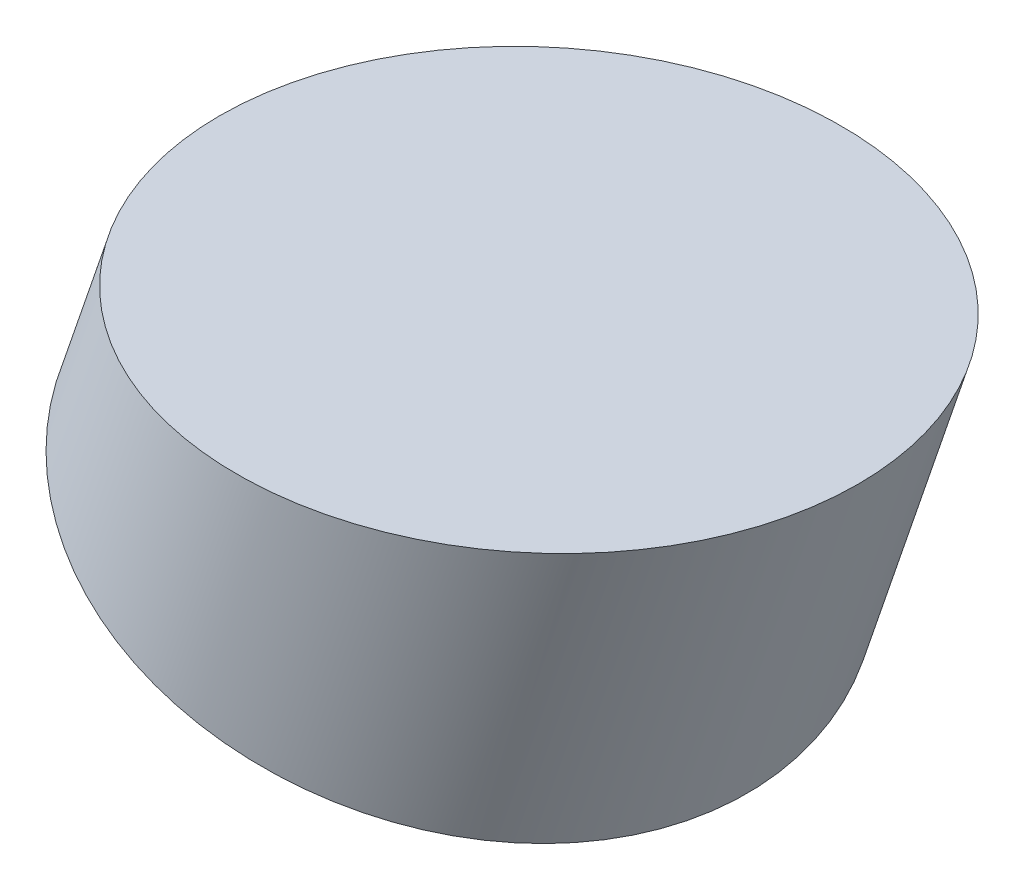
from build123d import *

# Parameters (mm, degrees)
BOSS_EXTRU_2_START      = 3
ESQUISSE3_R             = 9.65
BOSS_EXTRU_2_DEPTH      = 20
ESQUISSE4_W             = 37.049595251
ESQUISSE4_H             = 16.713526767
ENL_V_MAT_EXTRU_1_DEPTH = 25


with BuildPart() as part:
    # Esquisse3 → Boss.-Extru.2 (new body)
    with BuildSketch(Plane(origin=(2.831761515, 8.246104274, 0), x_dir=(0.945786581, -0.324788767, 0), z_dir=(0.324788767, 0.945786581, 0)).offset(BOSS_EXTRU_2_START)):
        with Locations((-0.112936213, -34.539256921)):
            Circle(ESQUISSE3_R)
    extrude(amount=BOSS_EXTRU_2_DEPTH)

    # Esquisse4 → Enlèv. mat.-Extru.1 (cut)
    with BuildSketch(Plane.XY.offset(45.039256921)):
        with Locations((11.108809322, 26.679267175)):
            Rectangle(ESQUISSE4_W, ESQUISSE4_H)
    extrude(amount=-ENL_V_MAT_EXTRU_1_DEPTH, mode=Mode.SUBTRACT)


solid = part.part
